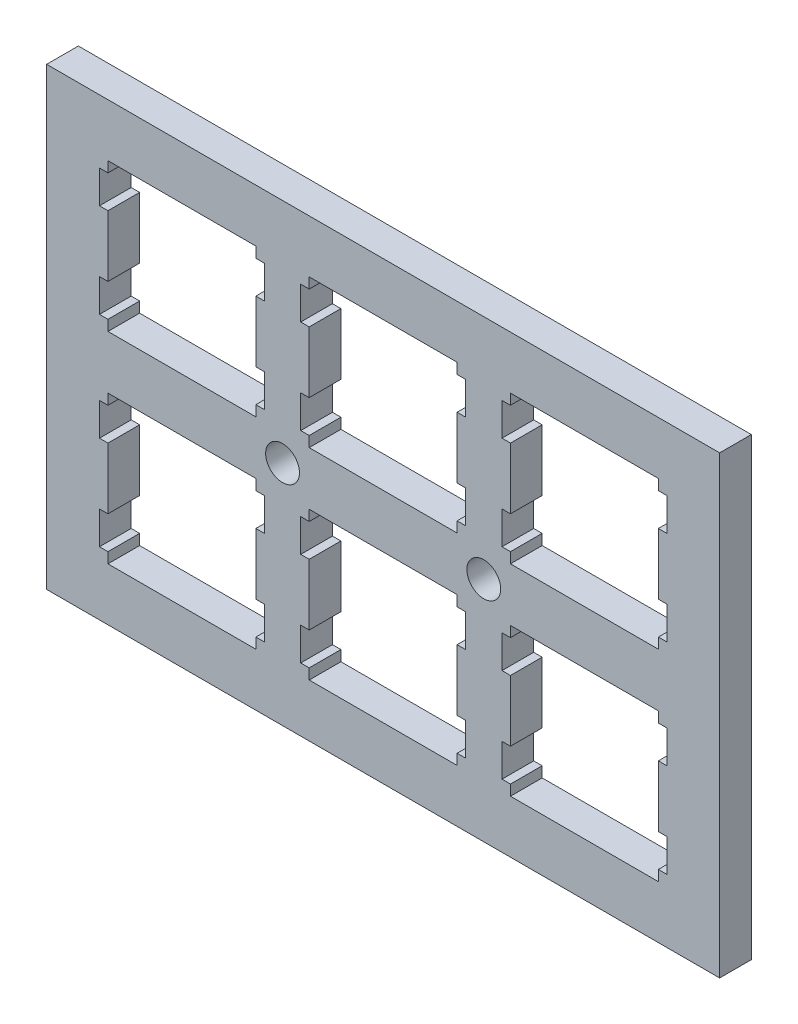
from build123d import *

# Parameters (mm, degrees)
MODEL_W         = 63.70079
MODEL_H         = 43.04936
MODEL_R         = 1.6
EXTRUDE_1_DEPTH = 3


with BuildPart() as part:
    # Model → 凸台-拉伸1 (new body)
    with BuildSketch(Plane.XY):
        with Locations((31.869154462, 21.443783961)):
            Rectangle(MODEL_W, MODEL_H)
        with Locations((22.344199462, 21.443163961)):
            Circle(MODEL_R, mode=Mode.SUBTRACT)
        with Locations((41.394099462, 21.443163961)):
            Circle(MODEL_R, mode=Mode.SUBTRACT)
        Polygon((43.919449462, 18.918563961), (43.919449462, 17.918163961), (43.118649462, 17.918163961), (43.118649462, 14.818963961), (43.919449462, 14.818963961), (43.919449462, 9.018753961), (43.118649462, 9.018753961), (43.118649462, 5.918193961), (43.919449462, 5.918193961), (43.919449462, 4.919103961), (57.918749462, 4.919103961), (57.918749462, 5.918193961), (58.719549462, 5.918193961), (58.719549462, 9.018753961), (57.918749462, 9.018753961), (57.918749462, 14.818963961), (58.719549462, 14.818963961), (58.719549462, 17.918163961), (57.918749462, 17.918163961), (57.918749462, 18.918563961), align=None, mode=Mode.SUBTRACT)
        Polygon((24.869449462, 18.918563961), (24.869449462, 17.918163961), (24.068749462, 17.918163961), (24.068749462, 14.818963961), (24.869449462, 14.818963961), (24.869449462, 9.018753961), (24.068749462, 9.018753961), (24.068749462, 5.918193961), (24.869449462, 5.918193961), (24.869449462, 4.919103961), (38.868749462, 4.919103961), (38.868749462, 5.918193961), (39.669549462, 5.918193961), (39.669549462, 9.018753961), (38.868749462, 9.018753961), (38.868749462, 14.818963961), (39.669549462, 14.818963961), (39.669549462, 17.918163961), (38.868749462, 17.918163961), (38.868749462, 18.918563961), align=None, mode=Mode.SUBTRACT)
        Polygon((5.819399462, 18.918563961), (5.819399462, 17.918163961), (5.018759462, 17.918163961), (5.018759462, 14.818963961), (5.819399462, 14.818963961), (5.819399462, 9.018753961), (5.018759462, 9.018753961), (5.018759462, 5.918193961), (5.819399462, 5.918193961), (5.819399462, 4.919103961), (19.818949462, 4.919103961), (19.818949462, 5.918193961), (20.619549462, 5.918193961), (20.619549462, 9.018753961), (19.818949462, 9.018753961), (19.818949462, 14.818963961), (20.619549462, 14.818963961), (20.619549462, 17.918163961), (19.818949462, 17.918163961), (19.818949462, 18.918563961), align=None, mode=Mode.SUBTRACT)
        Polygon((43.919449462, 37.968463961), (43.919449462, 36.968163961), (43.118649462, 36.968163961), (43.118649462, 33.868963961), (43.919449462, 33.868963961), (43.919449462, 28.068763961), (43.118649462, 28.068763961), (43.118649462, 24.968163961), (43.919449462, 24.968163961), (43.919449462, 23.969063961), (57.918749462, 23.969063961), (57.918749462, 24.968163961), (58.719549462, 24.968163961), (58.719549462, 28.068763961), (57.918749462, 28.068763961), (57.918749462, 33.868963961), (58.719549462, 33.868963961), (58.719549462, 36.968163961), (57.918749462, 36.968163961), (57.918749462, 37.968463961), align=None, mode=Mode.SUBTRACT)
        Polygon((24.869449462, 37.968463961), (24.869449462, 36.968163961), (24.068749462, 36.968163961), (24.068749462, 33.868963961), (24.869449462, 33.868963961), (24.869449462, 28.068763961), (24.068749462, 28.068763961), (24.068749462, 24.968163961), (24.869449462, 24.968163961), (24.869449462, 23.969063961), (38.868749462, 23.969063961), (38.868749462, 24.968163961), (39.669549462, 24.968163961), (39.669549462, 28.068763961), (38.868749462, 28.068763961), (38.868749462, 33.868963961), (39.669549462, 33.868963961), (39.669549462, 36.968163961), (38.868749462, 36.968163961), (38.868749462, 37.968463961), align=None, mode=Mode.SUBTRACT)
        Polygon((5.819399462, 37.968463961), (5.819399462, 36.968163961), (5.018759462, 36.968163961), (5.018759462, 33.868963961), (5.819399462, 33.868963961), (5.819399462, 28.068763961), (5.018759462, 28.068763961), (5.018759462, 24.968163961), (5.819399462, 24.968163961), (5.819399462, 23.969063961), (19.818949462, 23.969063961), (19.818949462, 24.968163961), (20.619549462, 24.968163961), (20.619549462, 28.068763961), (19.818949462, 28.068763961), (19.818949462, 33.868963961), (20.619549462, 33.868963961), (20.619549462, 36.968163961), (19.818949462, 36.968163961), (19.818949462, 37.968463961), align=None, mode=Mode.SUBTRACT)
    extrude(amount=EXTRUDE_1_DEPTH)


solid = part.part
